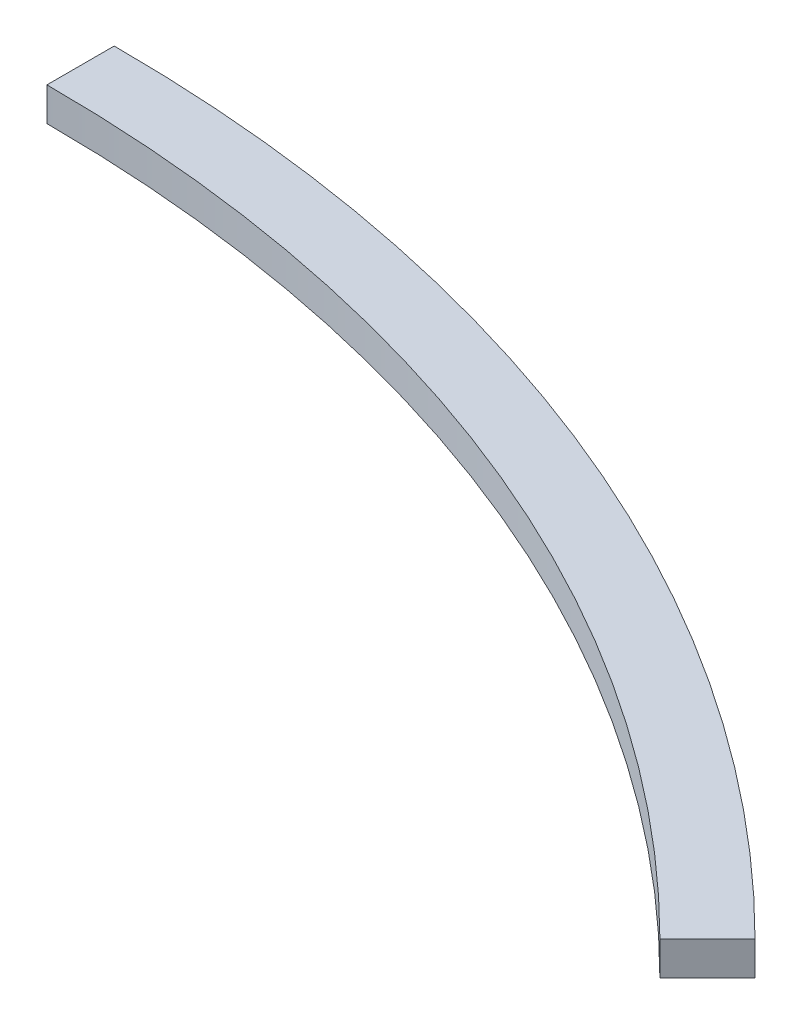
from build123d import *

# Parameters (mm, degrees)
BOSS_EXTRUDE1_DEPTH = 10


with BuildPart() as part:
    # Sketch1 → Boss-Extrude1 (new body)
    with BuildSketch(Plane(origin=(0, 0, 0), x_dir=(1, 0, 0), z_dir=(0, 1, 0))):
        with BuildLine():
            ThreePointArc((0, 460), (176.034378888, 424.984584955), (325.269119346, 325.269119346))
            Line((325.269119346, 325.269119346), (311.126983722, 311.126983722))
            ThreePointArc((311.126983722, 311.126983722), (168.380710241, 406.506994305), (0, 440))
            Line((0, 440), (0, 460))
        make_face()
    extrude(amount=BOSS_EXTRUDE1_DEPTH)


solid = part.part
